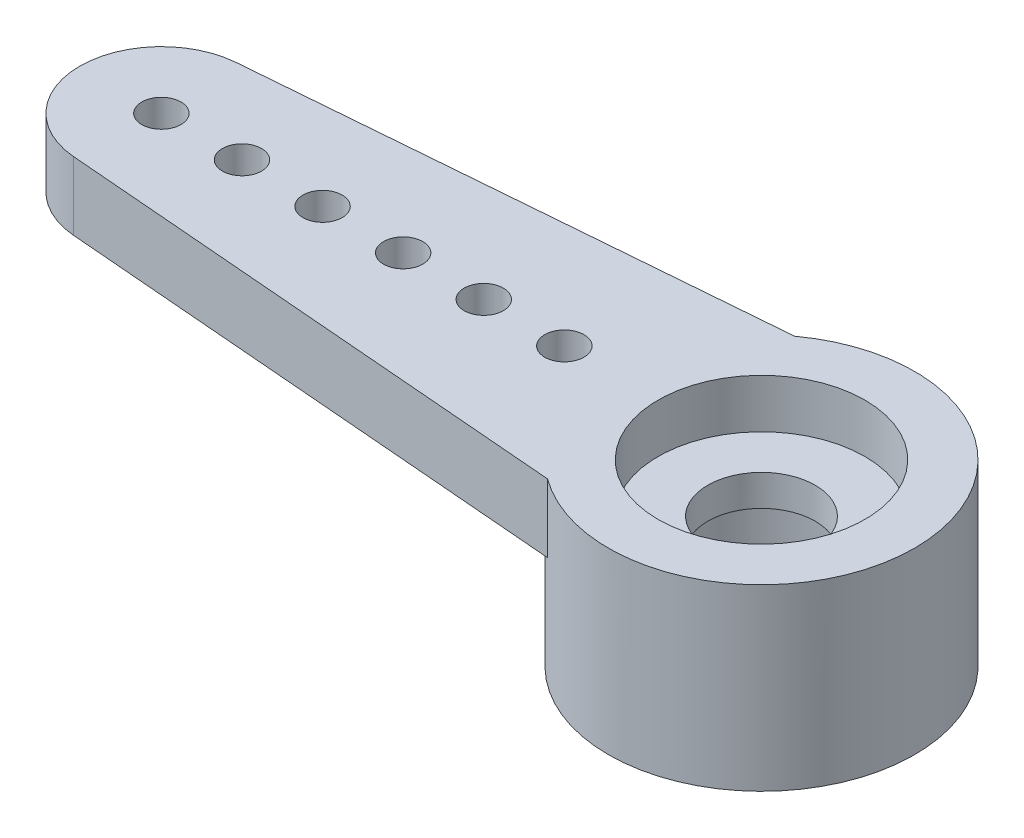
from build123d import *

# Parameters (mm, degrees)
EXTRUDE17_DEPTH = 1.6129
SKETCH19_R      = 3.6195
EXTRUDE19_DEPTH = 4.2291
SKETCH20_R      = 0.46355
SKETCH20_R_2    = 1.27
EXTRUDE20_DEPTH = 5.2291
SKETCH21_R      = 2.44475
EXTRUDE21_DEPTH = 1.1557
SKETCH22_R      = 2.286
EXTRUDE22_DEPTH = 2.3368


with BuildPart() as part:
    # Sketch18 → Extrude17 (new body)
    with BuildSketch(Plane(origin=(0, 0, 0), x_dir=(1, 0, 0), z_dir=(0, 1, 0))):
        with BuildLine():
            Line((-14.34305969, 1.923991942), (-2.13741415, 2.921))
            ThreePointArc((-2.13741415, 2.921), (3.6195, 0), (-2.13741415, -2.921))
            Line((-2.13741415, -2.921), (-14.34305969, -1.923991942))
            ThreePointArc((-14.34305969, -1.923991942), (-16.1163, 0), (-14.34305969, 1.923991942))
        make_face()
    extrude(amount=EXTRUDE17_DEPTH)

    # Sketch19 → Extrude19 (add)
    with BuildSketch(Plane(origin=(0, 1.6129, 0), x_dir=(1, 0, 0), z_dir=(0, 1, 0))):
        Circle(SKETCH19_R)
    extrude(amount=-EXTRUDE19_DEPTH)

    # Sketch20 → Extrude20 (cut, through all)
    with BuildSketch(Plane(origin=(0, 1.6129, 0), x_dir=(1, 0, 0), z_dir=(0, 1, 0))):
        with Locations((-14.1859, 0)):
            Circle(SKETCH20_R)
        Circle(SKETCH20_R_2)
        with Locations((-4.6609, 0)):
            Circle(SKETCH20_R)
        with Locations((-6.5659, 0)):
            Circle(SKETCH20_R)
        with Locations((-8.4709, 0)):
            Circle(SKETCH20_R)
        with Locations((-10.3759, 0)):
            Circle(SKETCH20_R)
        with Locations((-12.2809, 0)):
            Circle(SKETCH20_R)
    extrude(amount=-EXTRUDE20_DEPTH, mode=Mode.SUBTRACT)

    # Sketch21 → Extrude21 (cut)
    with BuildSketch(Plane(origin=(0, 1.6129, 0), x_dir=(1, 0, 0), z_dir=(0, 1, 0))):
        Circle(SKETCH21_R)
    extrude(amount=-EXTRUDE21_DEPTH, mode=Mode.SUBTRACT)

    # Sketch22 → Extrude22 (cut)
    with BuildSketch(Plane.XZ.offset(2.6162)):
        Circle(SKETCH22_R)
    extrude(amount=-EXTRUDE22_DEPTH, mode=Mode.SUBTRACT)


solid = part.part
